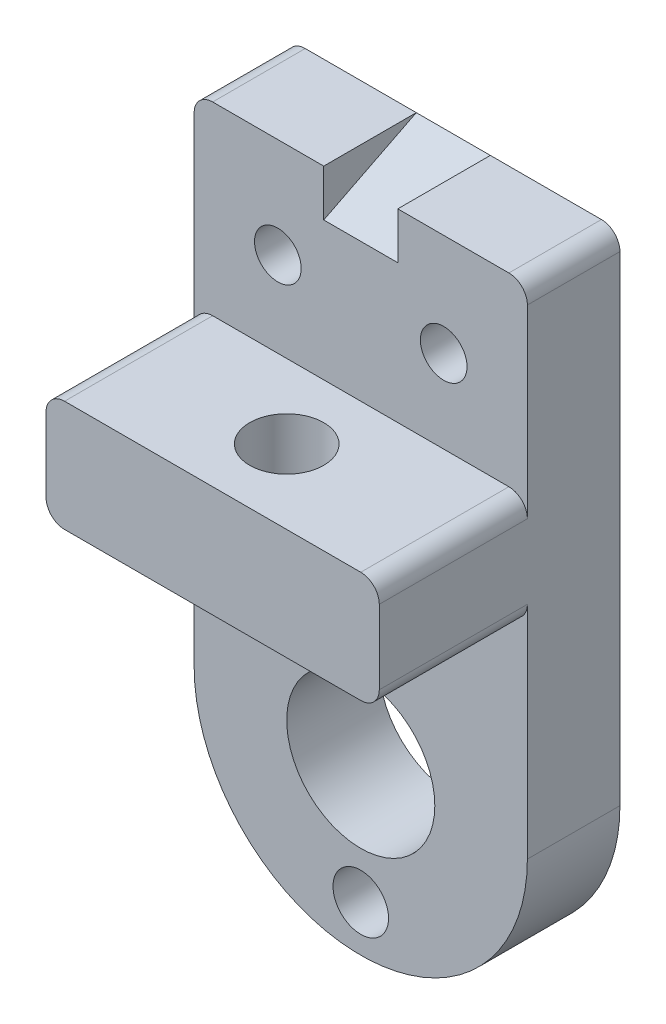
from build123d import *

# Parameters (mm, degrees)
CROQUIS1_R                = 8.001
SALIENTE_EXTRUIR1_DEPTH   = 31.75
CROQUIS1_R_2              = 6.35
CROQUIS1_R_3              = 9.525
CROQUIS1_R_4              = 25.4
SALIENTE_EXTRUIR1_2_DEPTH = 31.75
SALIENTE_EXTRUIR2_DEPTH   = 82.55
CORTAR_EXTRUIR1_REACH     = 194.798
CROQUIS3_R                = 12.7
SALIENTE_EXTRUIR3_REACH   = 204.274


with BuildPart() as part:
    # Croquis1 → Saliente-Extruir1 (new body)
    with BuildSketch(Plane.XY):
        with BuildLine():
            Line((50.8, 170.942), (12.7, 170.942))
            Line((12.7, 170.942), (12.7, 154.94))
            Line((12.7, 154.94), (-12.7, 154.94))
            Line((-12.7, 154.94), (-12.7, 170.942))
            Line((-12.7, 170.942), (-50.8, 170.942))
            ThreePointArc((-50.8, 170.942), (-55.290128061, 169.082128061), (-57.15, 164.592))
            Line((-57.15, 164.592), (-57.15, 101.092))
            ThreePointArc((-57.15, 101.092), (-55.290128061, 105.582128061), (-50.8, 107.442))
            Line((-50.8, 107.442), (50.8, 107.442))
            ThreePointArc((50.8, 107.442), (55.290128061, 105.582128061), (57.15, 101.092))
            Line((57.15, 101.092), (57.15, 164.592))
            ThreePointArc((57.15, 164.592), (55.290128061, 169.082128061), (50.8, 170.942))
        make_face()
        with Locations((-28.448, 136.652)):
            Circle(CROQUIS1_R, mode=Mode.SUBTRACT)
        with Locations((28.448, 135.89)):
            Circle(CROQUIS1_R, mode=Mode.SUBTRACT)
    extrude(amount=SALIENTE_EXTRUIR1_DEPTH)



with BuildPart() as body_2:
    # Croquis1 → Saliente-Extruir1 2 (new body)
    with BuildSketch(Plane.XY):
        with BuildLine():
            Line((57.15, 0), (57.15, 75.692))
            ThreePointArc((57.15, 75.692), (55.290128061, 71.201871939), (50.8, 69.342))
            Line((50.8, 69.342), (-50.8, 69.342))
            ThreePointArc((-50.8, 69.342), (-55.290128061, 71.201871939), (-57.15, 75.692))
            Line((-57.15, 75.692), (-57.15, 0))
            ThreePointArc((-57.15, 0), (0, -57.15), (57.15, 0))
        make_face()
        with Locations((-28.702, 41.402)):
            Circle(CROQUIS1_R_2, mode=Mode.SUBTRACT)
        with Locations((0, -41.402)):
            Circle(CROQUIS1_R_3, mode=Mode.SUBTRACT)
        Circle(CROQUIS1_R_4, mode=Mode.SUBTRACT)
    extrude(amount=SALIENTE_EXTRUIR1_2_DEPTH)


with BuildPart() as part_1:
    add(part.part)

    add(body_2.part)  # Saliente-Extruir2 merges body 2
    # Croquis1_3 → Saliente-Extruir2 (add)
    with BuildSketch(Plane.XY):
        with BuildLine():
            Line((57.15, 75.692), (57.15, 101.092))
            ThreePointArc((57.15, 101.092), (55.290128061, 105.582128061), (50.8, 107.442))
            Line((50.8, 107.442), (-50.8, 107.442))
            ThreePointArc((-50.8, 107.442), (-55.290128061, 105.582128061), (-57.15, 101.092))
            Line((-57.15, 101.092), (-57.15, 75.692))
            ThreePointArc((-57.15, 75.692), (-55.290128061, 71.201871939), (-50.8, 69.342))
            Line((-50.8, 69.342), (50.8, 69.342))
            ThreePointArc((50.8, 69.342), (55.290128061, 71.201871939), (57.15, 75.692))
        make_face()
    extrude(amount=SALIENTE_EXTRUIR2_DEPTH)

    # Croquis3 → Cortar-Extruir1 (cut, up to next)
    with BuildSketch(Plane(origin=(0, 107.442, 0), x_dir=(1, 0, 0), z_dir=(0, 1, 0)), mode=Mode.PRIVATE) as cortar_extruir1_sk1:
        with Locations((0, -57.15)):
            Circle(CROQUIS3_R)
    cortar_extruir1_tool1 = extrude(cortar_extruir1_sk1.sketch, amount=-CORTAR_EXTRUIR1_REACH, mode=Mode.PRIVATE) & part_1.part
    add(cortar_extruir1_tool1.solids().sort_by_distance((0, 107.442, 57.15))[0], mode=Mode.SUBTRACT)

    # Croquis4 → Saliente-Extruir3 (add, up to next)
    with BuildSketch(Plane.ZY.offset(-12.7), mode=Mode.PRIVATE) as saliente_extruir3_sk1:
        Polygon((31.75, 154.94), (0, 170.942), (0, 154.94), align=None)
    saliente_extruir3_tool1 = extrude(saliente_extruir3_sk1.sketch, amount=SALIENTE_EXTRUIR3_REACH, mode=Mode.PRIVATE) - part_1.part
    add(saliente_extruir3_tool1.solids().sort_by_distance((12.7, 160.274, 10.583333))[0])


solid = part_1.part
